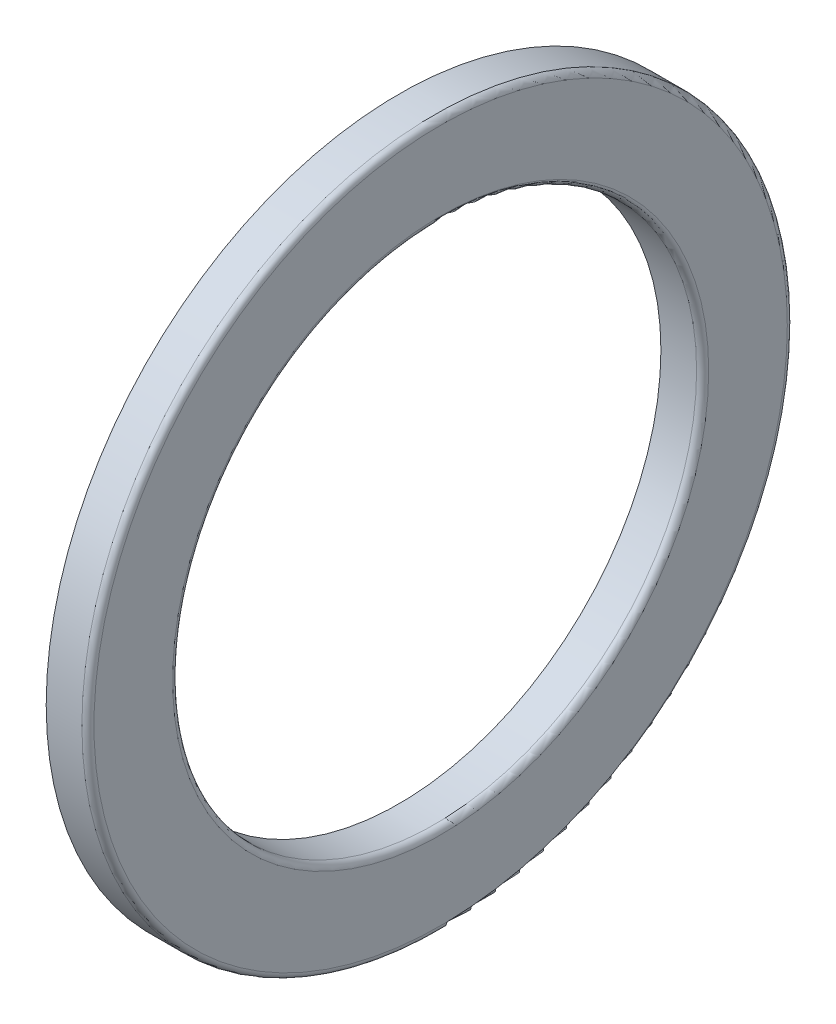
from build123d import *


with BuildPart() as part:
    # Croquis1 → Revolución1 (revolve)
    with BuildSketch(Plane.XY):
        with BuildLine():
            Line((9.858, 26), (13.4, 26))
            ThreePointArc((13.4, 26), (13.824264069, 26.175735931), (14, 26.6))
            Line((14, 26.6), (14, 34.4))
            ThreePointArc((14, 34.4), (13.824264069, 34.824264069), (13.4, 35))
            Line((13.4, 35), (9.858, 35))
            Line((9.858, 35), (9.858, 32.142666563))
            ThreePointArc((9.858, 32.142666563), (10.572, 30), (9.858, 27.857333437))
            Line((9.858, 27.857333437), (9.858, 26))
        make_face()
    revolve(axis=Axis((13.4, 0, 0), (-1, 0, 0)))


solid = part.part
